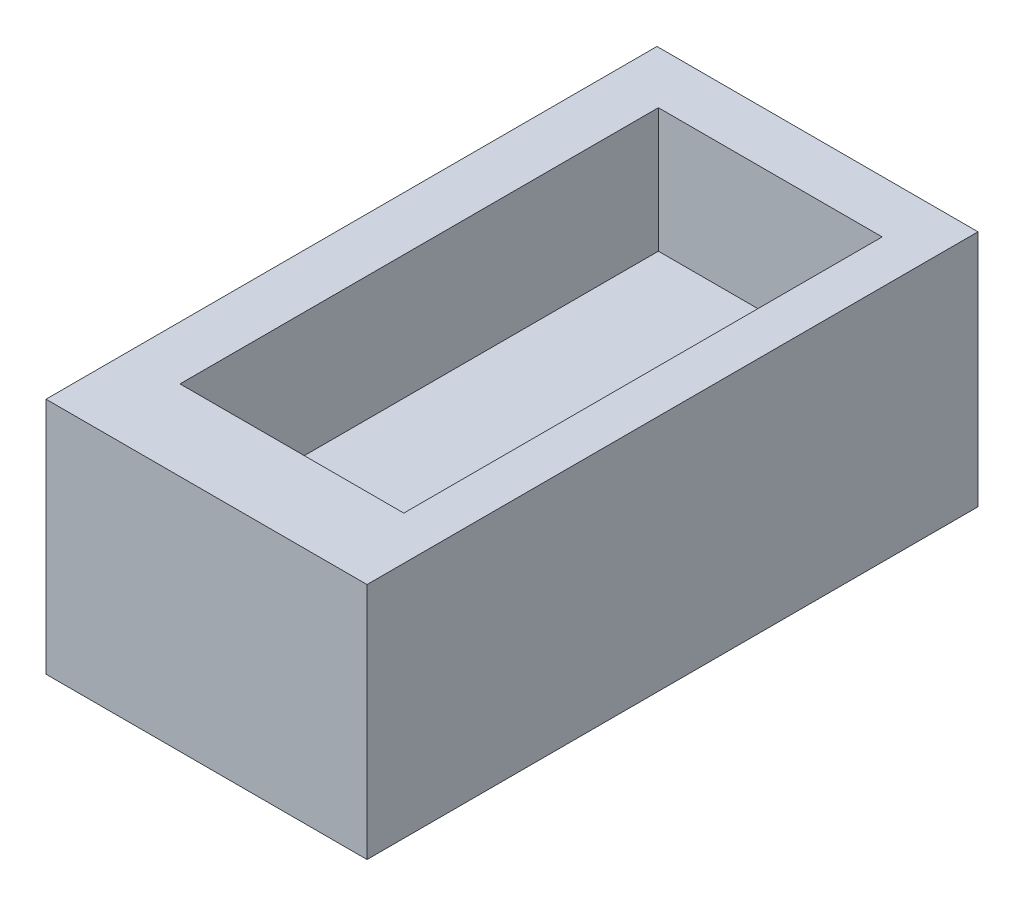
from build123d import *

# Parameters (mm, degrees)
SKETCH1_W           = 31
SKETCH1_H           = 59
BOSS_EXTRUDE1_DEPTH = 23
SKETCH2_W           = 21.609196656
SKETCH2_H           = 46.19436878
CUT_EXTRUDE1_DEPTH  = 12


with BuildPart() as part:
    # Sketch1 → Boss-Extrude1 (new body)
    with BuildSketch(Plane(origin=(0, 0, 0), x_dir=(1, 0, 0), z_dir=(0, 1, 0))):
        Rectangle(SKETCH1_W, SKETCH1_H)
    extrude(amount=BOSS_EXTRUDE1_DEPTH)

    # Sketch2 → Cut-Extrude1 (cut)
    with BuildSketch(Plane(origin=(0, 23, 0), x_dir=(1, 0, 0), z_dir=(0, 1, 0))):
        with Locations((0.497133186, 1.347240935)):
            Rectangle(SKETCH2_W, SKETCH2_H)
    extrude(amount=-CUT_EXTRUDE1_DEPTH, mode=Mode.SUBTRACT)


solid = part.part
